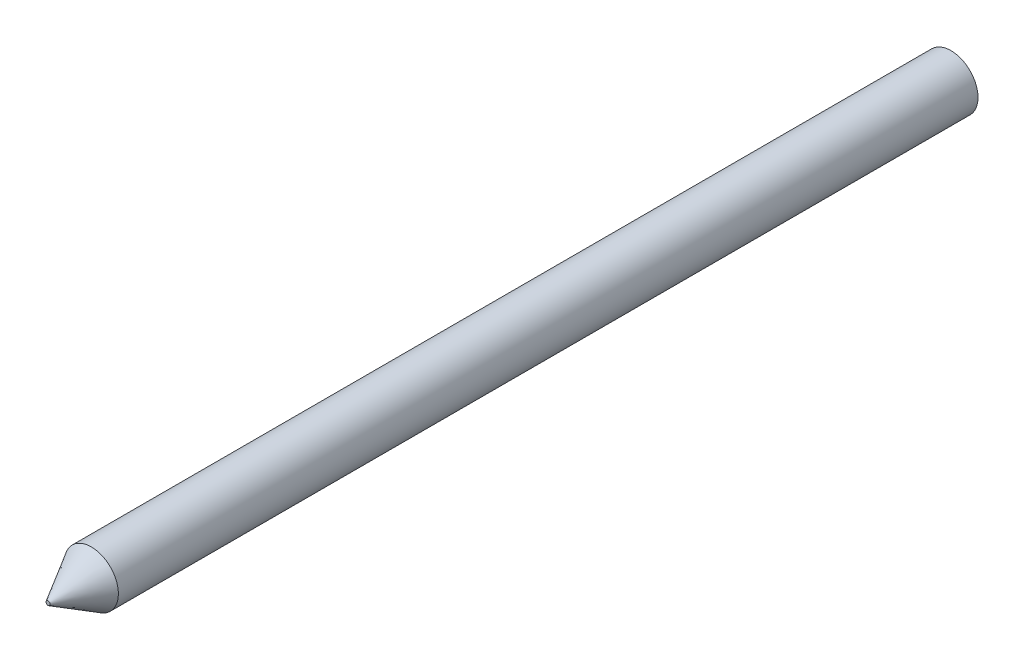
from build123d import *

# Parameters (mm, degrees)
SKETCH1_R           = 7.5
BOSS_EXTRUDE1_DEPTH = 250.35
CHAMFER1_SIZE       = 12
CHAMFER1_SIZE2      = 6.92820323


with BuildPart() as part:
    # Sketch1 → Boss-Extrude1 (new body)
    with BuildSketch(Plane.XY):
        with Locations((-256.609003688, 0)):
            Circle(SKETCH1_R)
    extrude(amount=BOSS_EXTRUDE1_DEPTH)

    # Chamfer1
    chamfer1_edges = [part.edges().sort_by_distance(p)[0] for p in [
        (-264.109003688, 0, 250.35),
    ]]
    chamfer1_side = [part.faces().sort_by_distance(p)[0] for p in [
        (-264.109003688, 0, 125.175),
    ]]
    chamfer(chamfer1_edges, length=CHAMFER1_SIZE, length2=CHAMFER1_SIZE2, reference=chamfer1_side[0])


solid = part.part
